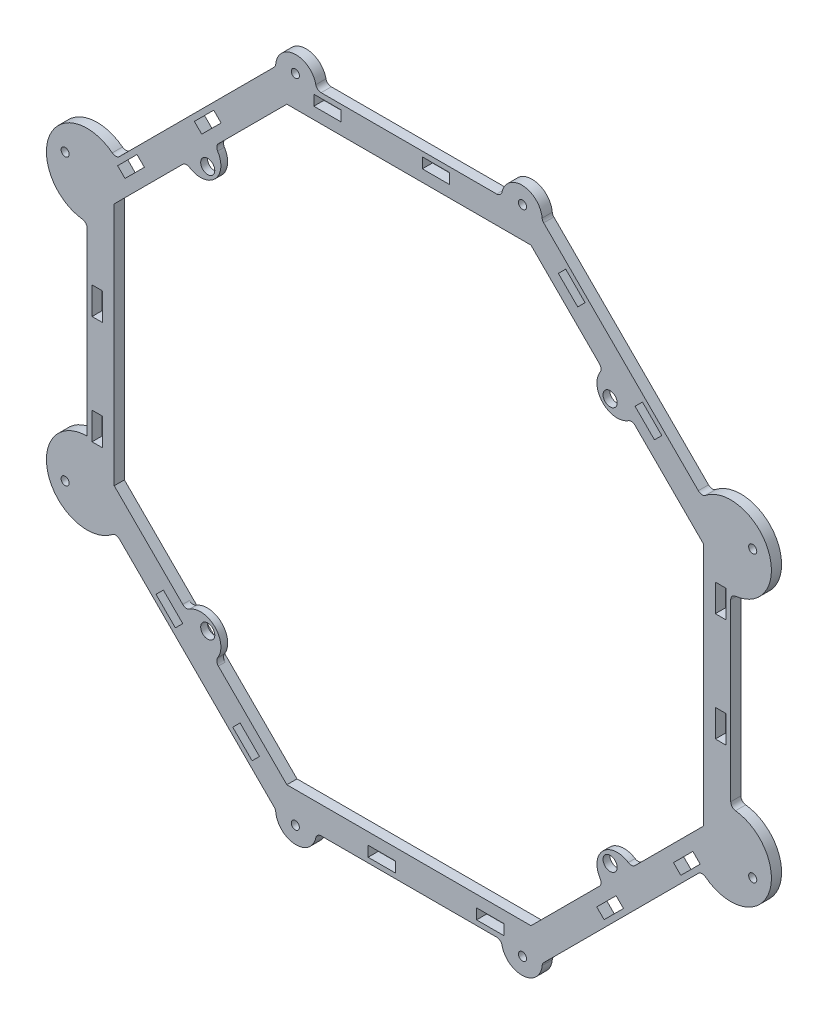
from build123d import *

# Parameters (mm, degrees)
BOSS_EXTRUDE1_DEPTH       = 4.7625
SKETCH2_R                 = 3.302
BOSS_EXTRUDE2_DEPTH       = 3.175
SKETCH3_W                 = 12.827
SKETCH3_H                 = 4.8768
SKETCH3_W_2               = 4.8768
SKETCH3_H_2               = 12.827
PANEL_SLOTS_DEPTH         = 5.7625
BOSS_EXTRUDE8_DEPTH       = 4.7625
F_6_CLEARANCE_HOLE2_D     = 3.7973
F_6_CLEARANCE_HOLE2_DEPTH = 25.4
F_6_CLEARANCE_HOLE2_TIP   = 1.140824014
BOSS_EXTRUDE9_DEPTH       = 4.7625
F_6_CLEARANCE_HOLE3_D     = 3.7973
F_6_CLEARANCE_HOLE3_DEPTH = 25.4
F_6_CLEARANCE_HOLE3_TIP   = 1.140824014
FILLET1_R                 = 2.54
FILLET2_R                 = 2.54


with BuildPart() as part:
    # Sketch1 → Boss-Extrude1 (new body)
    with BuildSketch(Plane.XY):
        Polygon((-150.669615327, -62.417005507), (-62.404018861, -150.674994572), (62.417005507, -150.669615327), (150.674994572, -62.404018861), (150.669615327, 62.417005507), (62.404018861, 150.674994572), (-62.417005507, 150.669615327), (-150.674994572, 62.404018861), align=None)
        Polygon((-137.969842044, -57.155945955), (-57.144053939, -137.974767879), (57.155945955, -137.969842044), (137.974767879, -57.144053939), (137.969842044, 57.155945955), (57.144053939, 137.974767879), (-57.155945955, 137.969842044), (-137.974767879, 57.144053939), align=None, mode=Mode.SUBTRACT)
    extrude(amount=BOSS_EXTRUDE1_DEPTH)

    # Sketch2 → Boss-Extrude2 (add)
    with BuildSketch(Plane.XY.offset(4.7625)):
        with BuildLine():
            Line((-104.300258744, 90.821465649), (-90.83045509, 104.292430334))
            ThreePointArc((-90.83045509, 104.292430334), (-90.829874575, 90.822046164), (-104.300258744, 90.821465649))
        make_face()
        with Locations((-94.197615746, 94.189497078)):
            Circle(SKETCH2_R, mode=Mode.SUBTRACT)
        with BuildLine():
            Line((104.292430334, 90.83045509), (90.821465649, 104.300258744))
            ThreePointArc((90.821465649, 104.300258744), (90.822046164, 90.829874575), (104.292430334, 90.83045509))
        make_face()
        with Locations((94.189497078, 94.197615746)):
            Circle(SKETCH2_R, mode=Mode.SUBTRACT)
        with BuildLine():
            Line((104.300258744, -90.821465649), (90.83045509, -104.292430334))
            ThreePointArc((90.83045509, -104.292430334), (90.829874575, -90.822046164), (104.300258744, -90.821465649))
        make_face()
        with Locations((94.197615746, -94.189497078)):
            Circle(SKETCH2_R, mode=Mode.SUBTRACT)
        with BuildLine():
            Line((-104.292430334, -90.83045509), (-90.821465649, -104.300258744))
            ThreePointArc((-90.821465649, -104.300258744), (-90.822046164, -90.829874575), (-104.292430334, -90.83045509))
        make_face()
        with Locations((-94.189497078, -94.197615746)):
            Circle(SKETCH2_R, mode=Mode.SUBTRACT)
    extrude(amount=-BOSS_EXTRUDE2_DEPTH)

    # Sketch3 → Panel Slots (cut, through all)
    with BuildSketch(Plane.XY.offset(4.7625)):
        with Locations((-38.105945973, 145.908163017)):
            Rectangle(SKETCH3_W, SKETCH3_H)
        with Locations((12.69405398, 145.910352276)):
            Rectangle(SKETCH3_W, SKETCH3_H)
        Polygon((82.486917215, 127.306804135), (73.416858533, 136.376862817), (69.968440182, 132.928444466), (79.038498864, 123.858385784), align=None)
        Polygon((114.961071356, 87.938909374), (105.891012674, 97.008968056), (109.339431024, 100.457386406), (118.409489706, 91.387327724), align=None)
        with Locations((145.908163017, 38.105945973)):
            Rectangle(SKETCH3_W_2, SKETCH3_H_2)
        with Locations((145.910352276, -12.69405398)):
            Rectangle(SKETCH3_W_2, SKETCH3_H_2)
        Polygon((127.306804135, -82.486917215), (136.376862817, -73.416858533), (132.928444466, -69.968440182), (123.858385784, -79.038498864), align=None)
        Polygon((87.938909374, -114.961071356), (97.008968056, -105.891012674), (100.457386406, -109.339431024), (91.387327724, -118.409489706), align=None)
        with Locations((38.105945973, -145.908163017)):
            Rectangle(SKETCH3_W, SKETCH3_H)
        with Locations((-12.69405398, -145.910352276)):
            Rectangle(SKETCH3_W, SKETCH3_H)
        Polygon((-82.486917215, -127.306804135), (-73.416858533, -136.376862817), (-69.968440182, -132.928444466), (-79.038498864, -123.858385784), align=None)
        Polygon((-114.961071356, -87.938909374), (-105.891012674, -97.008968056), (-109.339431024, -100.457386406), (-118.409489706, -91.387327724), align=None)
        with Locations((-145.908163017, -38.105945973)):
            Rectangle(SKETCH3_W_2, SKETCH3_H_2)
        with Locations((-145.910352276, 12.69405398)):
            Rectangle(SKETCH3_W_2, SKETCH3_H_2)
        Polygon((-127.306804135, 82.486917215), (-136.376862817, 73.416858533), (-132.928444466, 69.968440182), (-123.858385784, 79.038498864), align=None)
        Polygon((-87.938909374, 114.961071356), (-97.008968056, 105.891012674), (-100.457386406, 109.339431024), (-91.387327724, 118.409489706), align=None)
    extrude(amount=-PANEL_SLOTS_DEPTH, mode=Mode.SUBTRACT)

    # Sketch9 → Boss-Extrude8 (add)
    with BuildSketch(Plane.XY.offset(4.7625)):
        with BuildLine():
            Line((-62.417005507, 150.669615327), (-43.367005525, 150.6704363))
            ThreePointArc((-43.367005525, 150.6704363), (-52.892416003, 160.195025805), (-62.417005507, 150.669615327))
        make_face()
        with BuildLine():
            Line((62.404018861, 150.674994572), (43.354018879, 150.6741736))
            ThreePointArc((43.354018879, 150.6741736), (52.878608384, 160.199584077), (62.404018861, 150.674994572))
        make_face()
        with BuildLine():
            Line((62.417005507, -150.669615327), (43.367005525, -150.6704363))
            ThreePointArc((43.367005525, -150.6704363), (52.892416003, -160.195025805), (62.417005507, -150.669615327))
        make_face()
        with BuildLine():
            Line((-62.404018861, -150.674994572), (-43.354018879, -150.6741736))
            ThreePointArc((-43.354018879, -150.6741736), (-52.878608384, -160.199584077), (-62.404018861, -150.674994572))
        make_face()
    extrude(amount=-BOSS_EXTRUDE8_DEPTH)

    # #6 Clearance Hole2
    with Locations(Plane.XY.offset(4.7625)):
        with Locations((-53.18125, 152.4), (53.18125, 152.4), (53.18125, -152.4), (-53.18125, -152.4), (0, 0)):
            Hole(F_6_CLEARANCE_HOLE2_D / 2, depth=F_6_CLEARANCE_HOLE2_DEPTH)
            with Locations((0, 0, -(F_6_CLEARANCE_HOLE2_DEPTH + F_6_CLEARANCE_HOLE2_TIP / 2))):  # 118° drill point
                Cone(0, F_6_CLEARANCE_HOLE2_D / 2, F_6_CLEARANCE_HOLE2_TIP, mode=Mode.SUBTRACT)

    # Sketch13 → Boss-Extrude9 (add)
    with BuildSketch(Plane.XY.offset(4.7625)):
        with BuildLine():
            Line((137.205190918, -75.874983545), (150.674994572, -62.404018861))
            Line((150.674994572, -62.404018861), (150.6741736, -43.354018879))
            ThreePointArc((150.6741736, -43.354018879), (168.275213823, -69.693379761), (137.205190918, -75.874983545))
        make_face()
        with BuildLine():
            Line((137.198650643, 75.886809161), (150.669615327, 62.417005507))
            Line((150.669615327, 62.417005507), (150.6704363, 43.367005525))
            ThreePointArc((150.6704363, 43.367005525), (168.269206233, 69.707883367), (137.198650643, 75.886809161))
        make_face()
        with BuildLine():
            Line((-150.674994581, 62.404018861), (-150.674173609, 43.354018879))
            ThreePointArc((-150.674173609, 43.354018879), (-168.275213832, 69.693379761), (-137.205190927, 75.874983545))
            Line((-137.205190927, 75.874983545), (-150.674994581, 62.404018861))
        make_face()
        with BuildLine():
            Line((-150.669615336, -62.417005507), (-150.670436308, -43.367005525))
            ThreePointArc((-150.670436308, -43.367005525), (-168.269206241, -69.707883367), (-137.198650652, -75.886809161))
            Line((-137.198650652, -75.886809161), (-150.669615336, -62.417005507))
        make_face()
    extrude(amount=-BOSS_EXTRUDE9_DEPTH)

    # #6 Clearance Hole3
    with Locations(Plane.XY.offset(4.7625)):
        with Locations((160.963744866, 66.681493332), (160.971633964, -66.668506668), (-160.963744823, -66.681493314), (-160.971634093, 66.668506686)):
            Hole(F_6_CLEARANCE_HOLE3_D / 2, depth=F_6_CLEARANCE_HOLE3_DEPTH)
            with Locations((0, 0, -(F_6_CLEARANCE_HOLE3_DEPTH + F_6_CLEARANCE_HOLE3_TIP / 2))):  # 118° drill point
                Cone(0, F_6_CLEARANCE_HOLE3_D / 2, F_6_CLEARANCE_HOLE3_TIP, mode=Mode.SUBTRACT)

    # Fillet1
    fillet1_edges = [part.edges().sort_by_distance(p)[0] for p in [
        (-62.417005507, 150.669615327, 2.38125),
        (62.404018861, 150.674994572, 2.38125),
        (62.417005507, -150.669615327, 2.38125),
        (-62.404018861, -150.674994572, 2.38125),
        (-43.367005525, 150.6704363, 2.38125),
        (43.354018879, 150.6741736, 2.38125),
        (43.367005525, -150.6704363, 2.38125),
        (-43.354018879, -150.6741736, 2.38125),
        (150.6704363, 43.367005525, 2.38125),
        (137.198650643, 75.886809161, 2.38125),
        (150.6741736, -43.354018879, 2.38125),
        (137.205190918, -75.874983545, 2.38125),
        (-137.198650652, -75.886809161, 2.38125),
        (-137.205190927, 75.874983545, 2.38125),
        (-150.674173609, 43.354018879, 2.38125),
    ]]
    fillet(fillet1_edges, radius=FILLET1_R)

    # Fillet2
    fillet2_edges = [part.edges().sort_by_distance(p)[0] for p in [
        (-90.83045509, 104.292430334, 3.175),
        (-104.300258744, 90.821465649, 3.175),
        (104.292430334, 90.83045509, 3.175),
        (90.821465649, 104.300258744, 3.175),
        (90.83045509, -104.292430334, 3.175),
        (104.300258744, -90.821465649, 3.175),
        (-104.292430334, -90.83045509, 3.175),
        (-90.821465649, -104.300258744, 3.175),
    ]]
    fillet(fillet2_edges, radius=FILLET2_R)


solid = part.part
